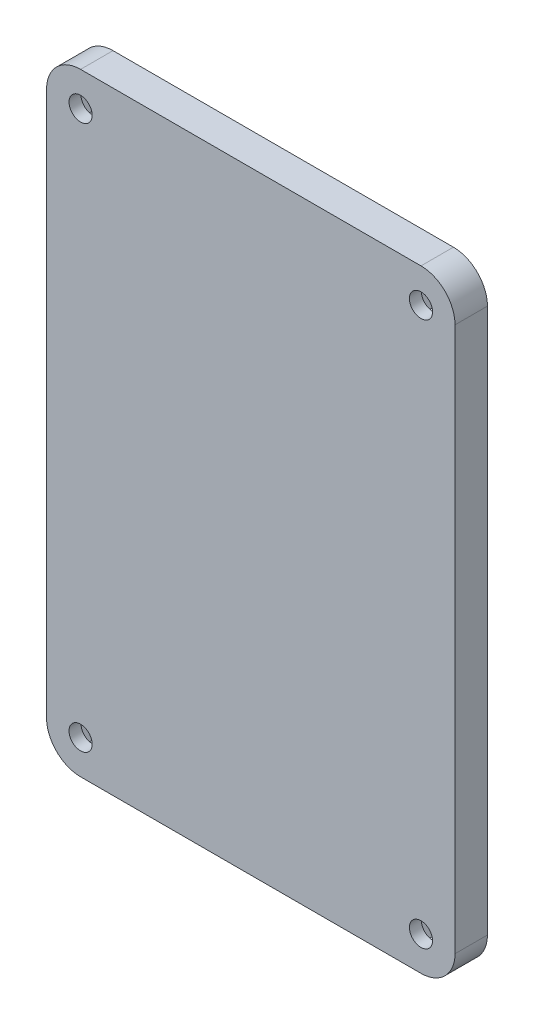
from build123d import *

# Parameters (mm, degrees)
SKETCH1_W           = 60
SKETCH1_H           = 90
BOSS_EXTRUDE1_DEPTH = 4.7625
FILLET1_R           = 5
SKETCH2_R           = 1.7
CUT_EXTRUDE1_DEPTH  = 5
CUT_EXTRUDE2_DEPTH  = 3


with BuildPart() as part:
    # Sketch1 → Boss-Extrude1 (new body)
    with BuildSketch(Plane.XY):
        Rectangle(SKETCH1_W, SKETCH1_H)
    extrude(amount=BOSS_EXTRUDE1_DEPTH)

    # Fillet1
    fillet1_edges = [part.edges().sort_by_distance(p)[0] for p in [
        (-30, 45, 2.38125),
        (30, 45, 2.38125),
        (30, -45, 2.38125),
        (-30, -45, 2.38125),
    ]]
    fillet(fillet1_edges, radius=FILLET1_R)

    # Sketch2 → Cut-Extrude1 (cut)
    with BuildSketch(Plane.XY):
        with Locations((-25, 40)):
            Circle(SKETCH2_R)
        with Locations((25, 40)):
            Circle(SKETCH2_R)
        with Locations((25, -40)):
            Circle(SKETCH2_R)
        with Locations((-25, -40)):
            Circle(SKETCH2_R)
    extrude(amount=CUT_EXTRUDE1_DEPTH, mode=Mode.SUBTRACT)

    # Sketch3 → Cut-Extrude2 (cut)
    with BuildSketch(Plane.XY):
        Polygon((-23.383419246, 37.2), (-21.766838493, 40), (-23.383419246, 42.8), (-26.616580754, 42.8), (-28.233161507, 40), (-26.616580754, 37.2), align=None)
        Polygon((26.616580754, 37.2), (28.233161507, 40), (26.616580754, 42.8), (23.383419246, 42.8), (21.766838493, 40), (23.383419246, 37.2), align=None)
        Polygon((26.616580754, -42.8), (28.233161507, -40), (26.616580754, -37.2), (23.383419246, -37.2), (21.766838493, -40), (23.383419246, -42.8), align=None)
        Polygon((-23.383419246, -42.8), (-21.766838493, -40), (-23.383419246, -37.2), (-26.616580754, -37.2), (-28.233161507, -40), (-26.616580754, -42.8), align=None)
    extrude(amount=CUT_EXTRUDE2_DEPTH, mode=Mode.SUBTRACT)


solid = part.part
